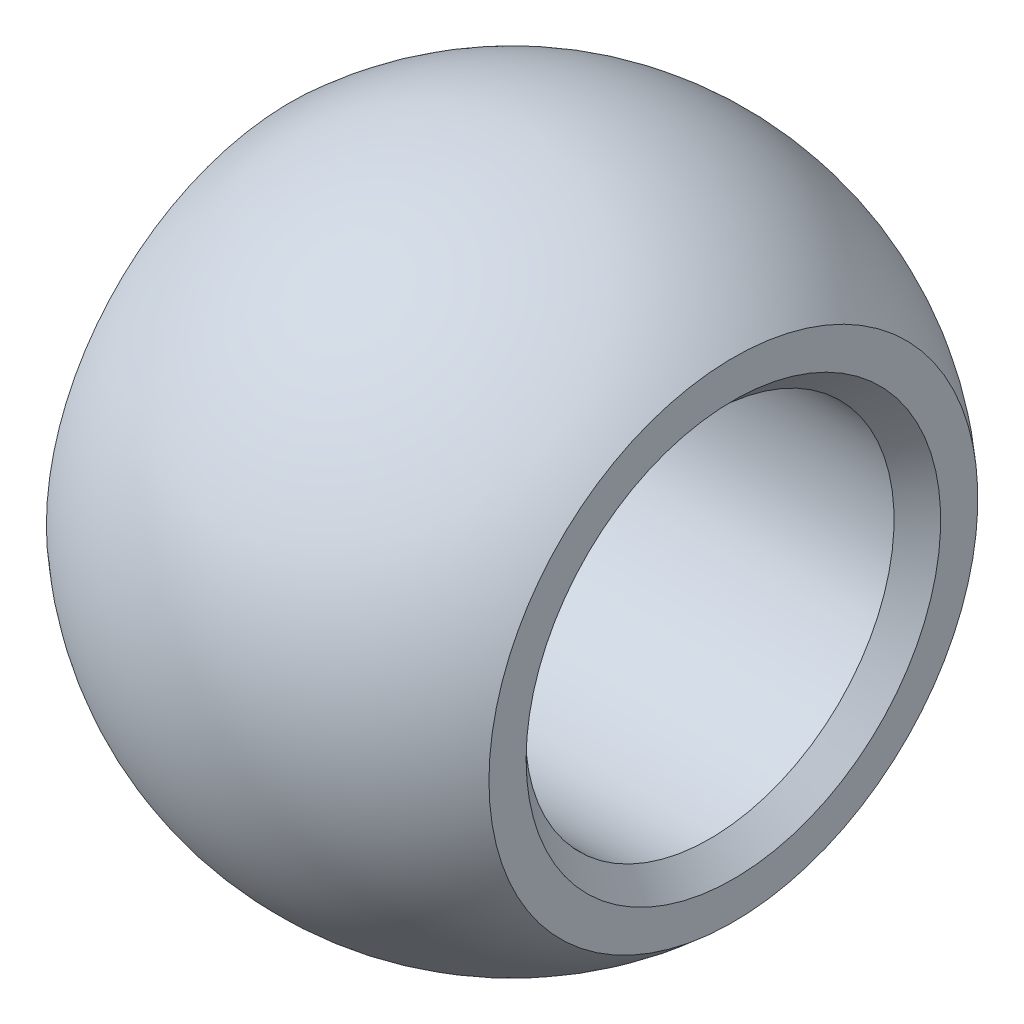
from build123d import *


with BuildPart() as part:
    # Sketch1 → Revolve1 (revolve)
    with BuildSketch(Plane.XY):
        with BuildLine():
            Line((-4.255, 3.97), (4.255, 3.97))
            Line((4.255, 3.97), (4.765, 4.463532559))
            Line((4.765, 4.463532559), (4.765, 5.263532559))
            ThreePointArc((4.765, 5.263532559), (0, 7.1), (-4.765, 5.263532559))
            Line((-4.765, 5.263532559), (-4.765, 4.463532559))
            Line((-4.765, 4.463532559), (-4.255, 3.97))
        make_face()
    revolve(axis=Axis((-4.765, 0, 0), (1, 0, 0)))


solid = part.part
